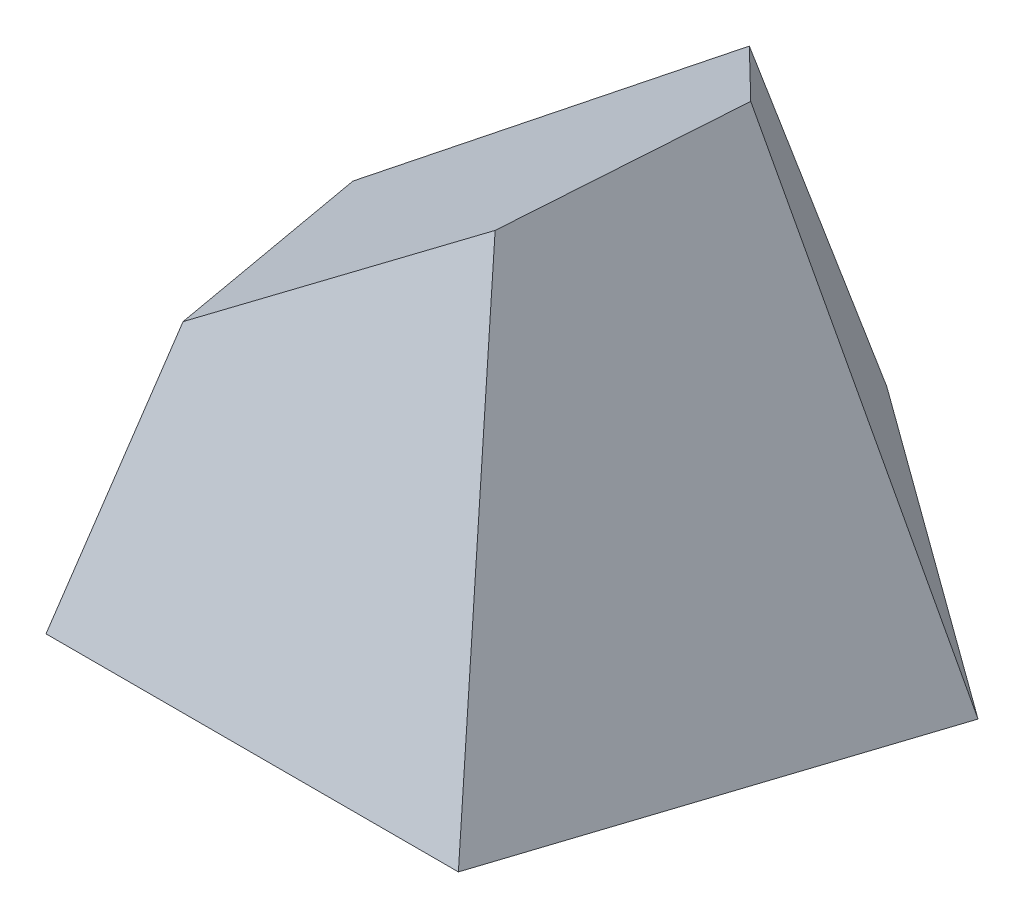
from build123d import *


with BuildPart() as part:
    # Sketch1 → Loft1 section 0
    with BuildSketch(Plane(origin=(0, 0, 0), x_dir=(1, 0, 0), z_dir=(0, 1, 0)), mode=Mode.PRIVATE) as loft1_s0:
        Polygon((70.360679775, -79.553670744), (82.72135955, -41.511410092), (50.360679775, -18), (18, -41.511410092), (30.360679775, -79.553670744), align=None)
    loft([Vertex(50.360679775, 90, 52.026032334), loft1_s0.sketch])

    # SurfaceCut1
    split(bisect_by=Plane(origin=(0, 0, 0), x_dir=(0.819152044, 0.573576436, 0), z_dir=(-0.573576436, 0.819152044, 0)), keep=Keep.BOTTOM)


solid = part.part
